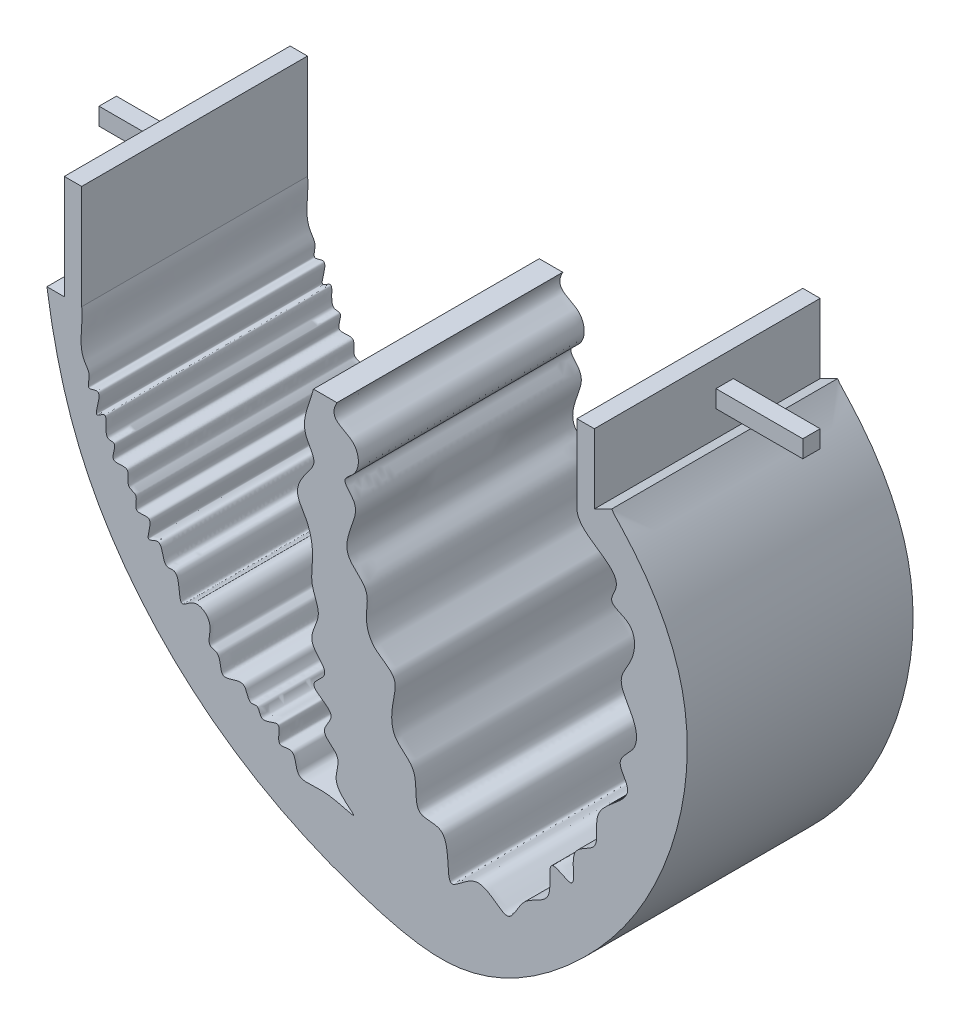
from build123d import *

# Parameters (mm, degrees)
BOSS_EXTRUDE1_DEPTH = 33.02
SKETCH2_W           = 2.54
SKETCH2_H           = 2.54
BOSS_EXTRUDE2_DEPTH = 12.7
SKETCH3_W           = 2.54
SKETCH3_H           = 2.54
BOSS_EXTRUDE3_DEPTH = 12.7


with BuildPart() as part:
    # Sketch1 → Boss-Extrude1 (new body)
    with BuildSketch(Plane.XY):
        with BuildLine():
            Line((155.989333214, 303.55217299), (158.529333214, 303.55217299))
            Line((158.529333214, 303.55217299), (158.529333214, 318.79217299))
            Line((158.529333214, 318.79217299), (161.069333214, 318.79217299))
            Line((161.069333214, 318.79217299), (161.069333214, 303.55217299))
            add(Edge.make_bspline(
                [(161.069333214, 303.55217299), (161.410718796, 301.513264647), (160.181391451, 297.999399523), (162.519217184, 295.577699128), (161.605590484, 293.26870494), (164.664329656, 294.931711017), (162.27901961, 289.833585605), (165.323907829, 292.617309397), (163.98220282, 288.495732376), (166.492842821, 288.881936552), (164.667456404, 285.661701403), (168.613727407, 287.081696864), (167.345906099, 284.046856942), (169.542549599, 283.841297304), (168.293856841, 281.067030497), (172.127688734, 282.503296625), (169.944834163, 278.129453115), (173.169747925, 280.331824351), (172.72007589, 276.446702931), (175.741245095, 277.393725668), (174.834707479, 271.780346672), (177.719374007, 275.13093893), (180.693618189, 272.950644943), (179.130644382, 269.932079788), (181.594929361, 269.70544762), (180.890278977, 265.74062862), (185.215469529, 268.850324677), (185.309756004, 265.438221207), (187.012140275, 266.062269973), (187.178602114, 263.620884118), (190.759796564, 266.316976206), (189.218368645, 261.889545476), (192.384556737, 263.338094534), (192.224062184, 259.014758747), (196.379463564, 260.561918149), (202.974451407, 257.947831475), (197.002323362, 261.668559241), (199.670322411, 265.418817741), (195.335032081, 267.323698037), (199.143171763, 270.569414149), (193.270736146, 272.343289264), (198.083023944, 274.988214009), (193.296432932, 277.882986585), (196.577647093, 281.633342825), (194.390135164, 285.006323033), (195.038771735, 288.854652972), (194.524163279, 292.560028251), (191.970285317, 295.800164445), (193.581450352, 298.595134968), (195.71436993, 301.016861391), (192.42661783, 304.654960988), (194.526049251, 308.067508221), (194.957752057, 310.074192577)],
                knots=[0, 0, 0, 0, 0.051397099, 0.063492278, 0.07499011, 0.084164581, 0.106718022, 0.115018682, 0.136469981, 0.141731233, 0.157651309, 0.172530237, 0.188746799, 0.195794784, 0.21024065, 0.223932447, 0.24329981, 0.253185315, 0.275037848, 0.281329768, 0.309961632, 0.324449574, 0.345972526, 0.366481674, 0.372547327, 0.3923408, 0.415464732, 0.430588624, 0.436356217, 0.446399471, 0.464593872, 0.482023296, 0.494082808, 0.511854457, 0.54217765, 0.575013905, 0.60269148, 0.629483694, 0.651571511, 0.671252835, 0.6991494, 0.718062159, 0.745128695, 0.7758905, 0.801425103, 0.826132826, 0.862249825, 0.884781126, 0.910268433, 0.927769514, 0.949733047, 1, 1, 1, 1], degree=3))
            Line((194.957752057, 310.074192577), (198.393897745, 310.074192577))
            add(Edge.make_bspline(
                [(198.393897745, 310.074192577), (196.915447653, 307.34898854), (201.603096528, 307.518127743), (201.834910175, 302.516226463), (198.739876768, 300.840935466), (201.665933407, 298.681721158), (200.484757514, 295.388724215), (198.999345505, 291.241370349), (203.418983169, 288.860017946), (202.363477489, 284.972651493), (203.462625417, 281.407786434), (207.574345548, 279.828476811), (206.292511734, 275.643602216), (206.311013715, 271.504161156), (210.833311208, 269.39823245), (209.076320884, 263.282570459), (215.615196685, 264.5807046), (213.548343037, 254.514732363), (219.255508953, 261.805020982), (223.596574731, 255.475841936), (225.409102594, 261.681824827), (230.556680826, 261.889000265), (228.664536323, 268.782374649), (234.027175711, 264.774709841), (231.790307916, 271.359891368), (237.304339276, 272.136674759), (234.985597896, 278.539198763), (242.8762486, 281.000941917), (238.737962858, 285.539463185), (242.42522432, 287.719555435), (242.168835113, 291.954059873), (238.840035328, 295.472438398), (242.019259766, 299.108516822), (242.263982755, 303.759120411), (237.76230795, 304.589064022), (241.380007542, 309.731740834), (233.62409352, 310.940387087), (233.488465065, 314.15917518)],
                knots=[0, 0, 0, 0, 0.037554978, 0.064865687, 0.078213309, 0.095176553, 0.117489449, 0.147696104, 0.176756278, 0.200024958, 0.224822208, 0.251288438, 0.27606956, 0.305558069, 0.331911923, 0.368045626, 0.388249502, 0.432206051, 0.462646707, 0.497672987, 0.524431732, 0.557499297, 0.585086392, 0.604402661, 0.633248701, 0.659676554, 0.689393401, 0.740627999, 0.760007537, 0.784769118, 0.807611373, 0.843275106, 0.868455507, 0.900645919, 0.920575352, 0.934057011, 1, 1, 1, 1], degree=3))
            Line((233.488465065, 314.15917518), (233.488465065, 325.58917518))
            Line((233.488465065, 325.58917518), (236.028465065, 325.58917518))
            Line((236.028465065, 325.58917518), (236.028465065, 315.42917518))
            Line((236.028465065, 315.42917518), (238.568465065, 316.69917518))
            add(Edge.make_bspline(
                [(155.989333214, 303.55217299), (156.98740616, 296.711766363), (160.903271147, 280.758367255), (177.679801191, 260.252616428), (198.008810058, 250.052656776), (218.121524923, 245.457478505), (234.434067504, 256.063238467), (247.820952481, 274.206001168), (252.025485834, 297.864311981), (243.492208313, 311.503972459), (238.944116053, 316.140928761), (238.568465065, 316.69917518)],
                knots=[0.120046572, 0.120046572, 0.120046572, 0.120046572, 0.184833858, 0.273021776, 0.359649237, 0.397816634, 0.461195161, 0.526426676, 0.612455038, 0.666069007, 0.672633998, 0.672633998, 0.672633998, 0.672633998], degree=3))
        make_face()
    extrude(amount=BOSS_EXTRUDE1_DEPTH)

    # Sketch2 → Boss-Extrude2 (add)
    with BuildSketch(Plane.ZY.offset(-158.529333214)):
        with Locations((13.97, 311.17217299)):
            Rectangle(SKETCH2_W, SKETCH2_H)
    extrude(amount=BOSS_EXTRUDE2_DEPTH)

    # Sketch3 → Boss-Extrude3 (add)
    with BuildSketch(Plane(origin=(236.028465065, 0, 0), x_dir=(0, 0, -1), z_dir=(1, 0, 0))):
        with Locations((-13.97, 320.50917518)):
            Rectangle(SKETCH3_W, SKETCH3_H)
    extrude(amount=BOSS_EXTRUDE3_DEPTH)


solid = part.part
